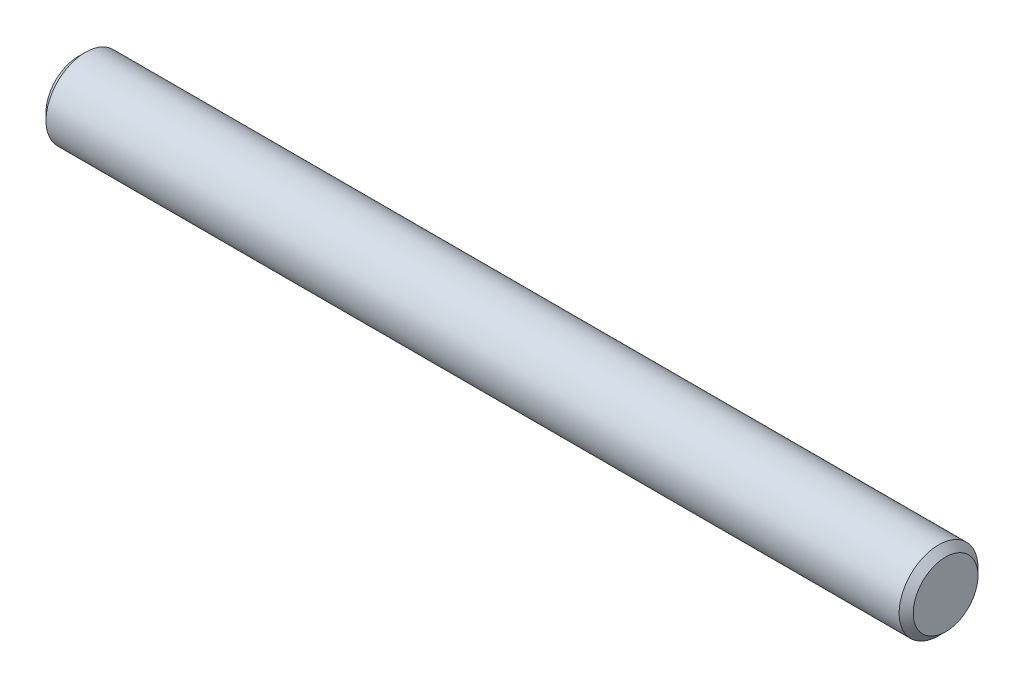
from build123d import *

# Parameters (mm, degrees)
BODYSKE_W     = 55
BODYSKE_H     = 2.5
CHAMFER1_SIZE = 0.445


with BuildPart() as part:
    # BodySke → BaseBody (revolve)
    with BuildSketch(Plane.XY):
        with Locations((27.5, 1.25)):
            Rectangle(BODYSKE_W, BODYSKE_H)
    revolve(axis=Axis((-3.175, 0, 0), (1, 0, 0)))

    # Chamfer1
    chamfer1_edges = [part.edges().sort_by_distance(p)[0] for p in [
        (0, -2.5, 0),
        (55, -2.5, 0),
    ]]
    chamfer(chamfer1_edges, length=CHAMFER1_SIZE)


solid = part.part
